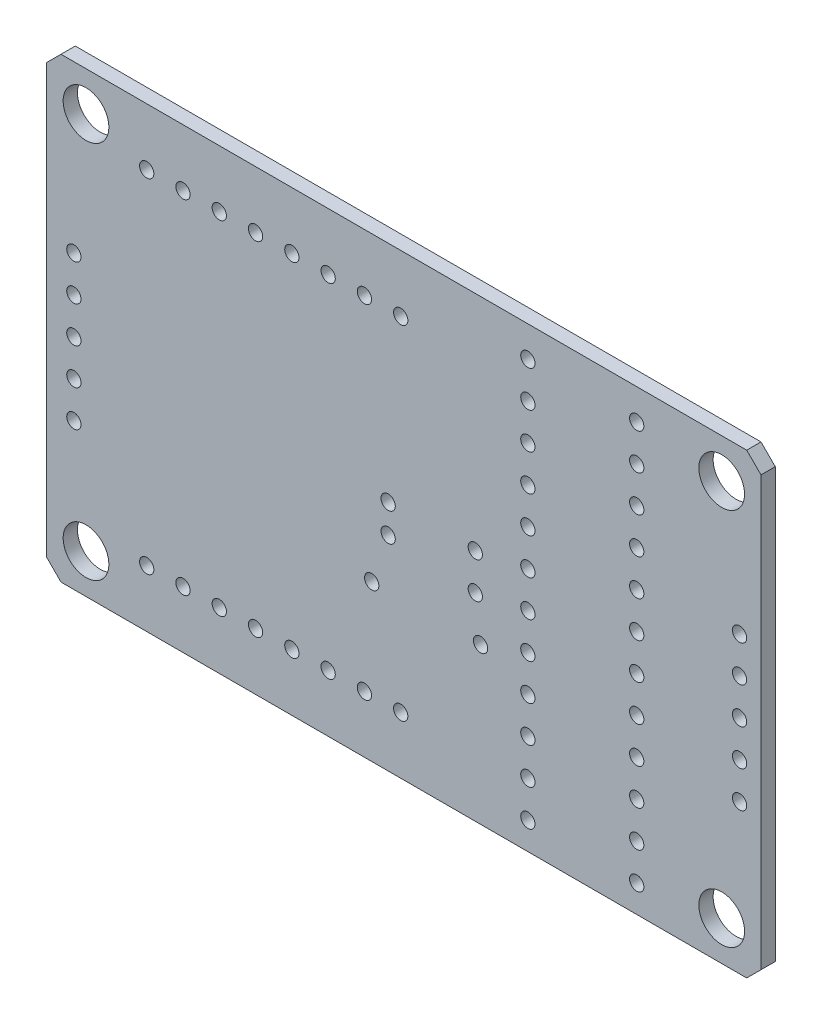
from build123d import *

# Parameters (mm, degrees)
SKETCH1_W           = 50
SKETCH1_H           = 32
SKETCH1_R           = 1.6
BOSS_EXTRUDE1_DEPTH = 1
SKETCH3_R           = 0.5
CUT_EXTRUDE1_DEPTH  = 1
CHAMFER1_SIZE       = 1


with BuildPart() as part:
    # Sketch1 → Boss-Extrude1 (new body)
    with BuildSketch(Plane.XY):
        Rectangle(SKETCH1_W, SKETCH1_H)
        with Locations((-22.25, -13.25)):
            Circle(SKETCH1_R, mode=Mode.SUBTRACT)
        with Locations((22.25, -13.25)):
            Circle(SKETCH1_R, mode=Mode.SUBTRACT)
        with Locations((22.25, 13.25)):
            Circle(SKETCH1_R, mode=Mode.SUBTRACT)
        with Locations((-22.25, 13.25)):
            Circle(SKETCH1_R, mode=Mode.SUBTRACT)
    extrude(amount=BOSS_EXTRUDE1_DEPTH)

    # Sketch3 → Cut-Extrude1 (cut)
    with BuildSketch(Plane(origin=(0, 0, 0), x_dir=(-1, 0, 0), z_dir=(0, 0, -1))):
        with Locations((-23.5, 4.6)):
            Circle(SKETCH3_R)
        with Locations((-23.5, 2.06)):
            Circle(SKETCH3_R)
        with Locations((-23.5, -0.48)):
            Circle(SKETCH3_R)
        with Locations((-23.5, -3.02)):
            Circle(SKETCH3_R)
        with Locations((-23.5, -5.56)):
            Circle(SKETCH3_R)
        with Locations((-16.3, 13.85)):
            Circle(SKETCH3_R)
        with Locations((-16.3, 11.31)):
            Circle(SKETCH3_R)
        with Locations((-16.3, 8.77)):
            Circle(SKETCH3_R)
        with Locations((-16.3, 6.23)):
            Circle(SKETCH3_R)
        with Locations((-16.3, 3.69)):
            Circle(SKETCH3_R)
        with Locations((-16.3, 1.15)):
            Circle(SKETCH3_R)
        with Locations((-16.3, -1.39)):
            Circle(SKETCH3_R)
        with Locations((-16.3, -3.93)):
            Circle(SKETCH3_R)
        with Locations((-16.3, -6.47)):
            Circle(SKETCH3_R)
        with Locations((-16.3, -9.01)):
            Circle(SKETCH3_R)
        with Locations((-16.3, -11.55)):
            Circle(SKETCH3_R)
        with Locations((-16.3, -14.09)):
            Circle(SKETCH3_R)
        with Locations((-8.68, 13.85)):
            Circle(SKETCH3_R)
        with Locations((-8.68, 11.31)):
            Circle(SKETCH3_R)
        with Locations((-8.68, 8.77)):
            Circle(SKETCH3_R)
        with Locations((-8.68, 6.23)):
            Circle(SKETCH3_R)
        with Locations((-8.68, 3.69)):
            Circle(SKETCH3_R)
        with Locations((-8.68, 1.15)):
            Circle(SKETCH3_R)
        with Locations((-8.68, -1.39)):
            Circle(SKETCH3_R)
        with Locations((-8.68, -3.93)):
            Circle(SKETCH3_R)
        with Locations((-8.68, -6.47)):
            Circle(SKETCH3_R)
        with Locations((-8.68, -9.01)):
            Circle(SKETCH3_R)
        with Locations((-8.68, -11.55)):
            Circle(SKETCH3_R)
        with Locations((-8.68, -14.09)):
            Circle(SKETCH3_R)
        with Locations((18, 12)):
            Circle(SKETCH3_R)
        with Locations((15.46, 12)):
            Circle(SKETCH3_R)
        with Locations((12.92, 12)):
            Circle(SKETCH3_R)
        with Locations((10.38, 12)):
            Circle(SKETCH3_R)
        with Locations((7.84, 12)):
            Circle(SKETCH3_R)
        with Locations((5.3, 12)):
            Circle(SKETCH3_R)
        with Locations((2.76, 12)):
            Circle(SKETCH3_R)
        with Locations((0.22, 12)):
            Circle(SKETCH3_R)
        with Locations((18, -12)):
            Circle(SKETCH3_R)
        with Locations((15.46, -12)):
            Circle(SKETCH3_R)
        with Locations((12.92, -12)):
            Circle(SKETCH3_R)
        with Locations((10.38, -12)):
            Circle(SKETCH3_R)
        with Locations((7.84, -12)):
            Circle(SKETCH3_R)
        with Locations((5.3, -12)):
            Circle(SKETCH3_R)
        with Locations((2.76, -12)):
            Circle(SKETCH3_R)
        with Locations((0.22, -12)):
            Circle(SKETCH3_R)
        with Locations((23.1, 4.4)):
            Circle(SKETCH3_R)
        with Locations((23.1, 1.86)):
            Circle(SKETCH3_R)
        with Locations((23.1, -0.68)):
            Circle(SKETCH3_R)
        with Locations((23.1, -3.22)):
            Circle(SKETCH3_R)
        with Locations((23.1, -5.76)):
            Circle(SKETCH3_R)
        with Locations((-5, 0.4)):
            Circle(SKETCH3_R)
        with Locations((-5, -2.14)):
            Circle(SKETCH3_R)
        with Locations((-5.37, -5.1)):
            Circle(SKETCH3_R)
        with Locations((2.25, -5.1)):
            Circle(SKETCH3_R)
        with Locations((1.1, 0.3)):
            Circle(SKETCH3_R)
        with Locations((1.1, -1.7)):
            Circle(SKETCH3_R)
    extrude(amount=-CUT_EXTRUDE1_DEPTH, mode=Mode.SUBTRACT)

    # Chamfer1
    chamfer1_edges = [part.edges().sort_by_distance(p)[0] for p in [
        (-25, 16, 0.5),
        (25, 16, 0.5),
        (25, -16, 0.5),
        (-25, -16, 0.5),
    ]]
    chamfer(chamfer1_edges, length=CHAMFER1_SIZE)


solid = part.part
